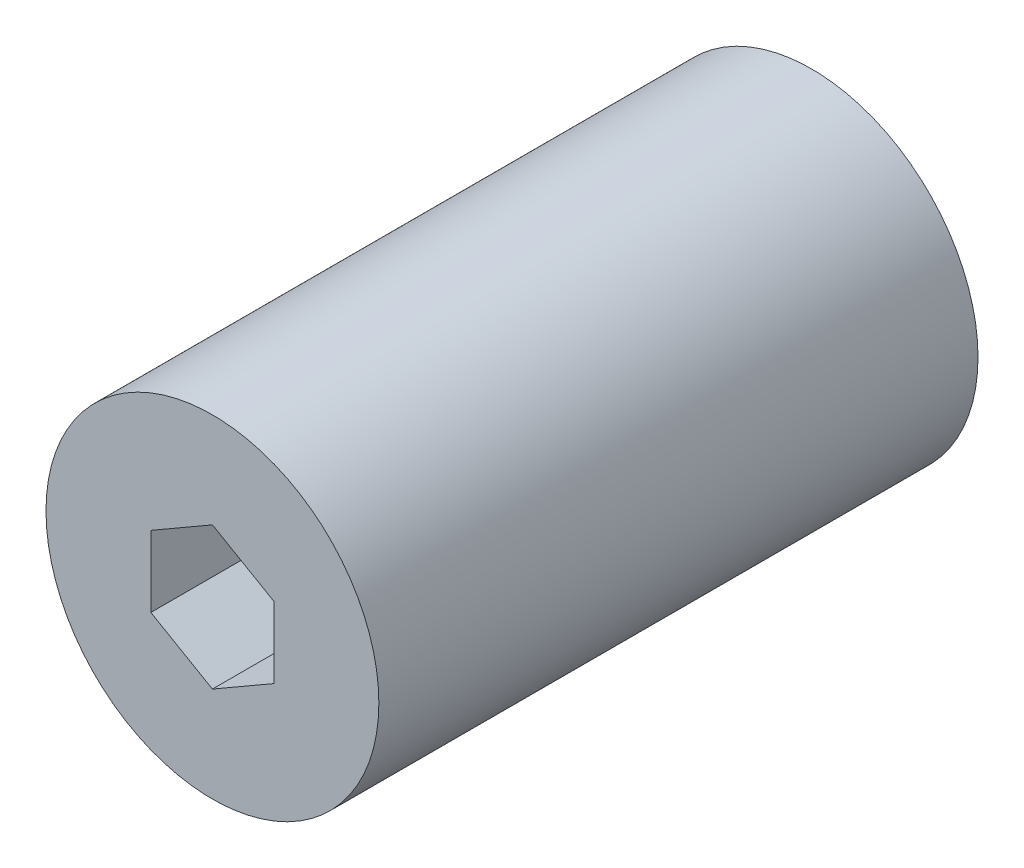
from build123d import *

# Parameters (mm, degrees)
ESBO_O2_R                = 10
RESSALTO_EXTRUS_O1_DEPTH = 36
CORTE_EXTRUS_O1_REACH    = 38
ESBO_O3_R                = 1.6
CORTE_EXTRUS_O2_DEPTH    = 15


with BuildPart() as part:
    # Esboço2 → Ressalto-extrusão1 (new body)
    with BuildSketch(Plane.XY):
        Circle(ESBO_O2_R)
    extrude(amount=RESSALTO_EXTRUS_O1_DEPTH)

    # Esboço3 → Corte-extrusão1 (cut, up to next)
    with BuildSketch(Plane.XY.offset(36), mode=Mode.PRIVATE) as corte_extrus_o1_sk1:
        Circle(ESBO_O3_R)
    corte_extrus_o1_tool1 = extrude(corte_extrus_o1_sk1.sketch, amount=-CORTE_EXTRUS_O1_REACH, mode=Mode.PRIVATE) & part.part
    add(corte_extrus_o1_tool1.solids().sort_by_distance((0, 0, 36))[0], mode=Mode.SUBTRACT)

    # Esboço4 → Corte-extrusão2 (cut)
    with BuildSketch(Plane.XY.offset(36)):
        Polygon((0, 4.272391992), (-3.7, 2.136195996), (-3.7, -2.136195996), (0, -4.272391992), (3.7, -2.136195996), (3.7, 2.136195996), align=None)
    extrude(amount=-CORTE_EXTRUS_O2_DEPTH, mode=Mode.SUBTRACT)


solid = part.part
